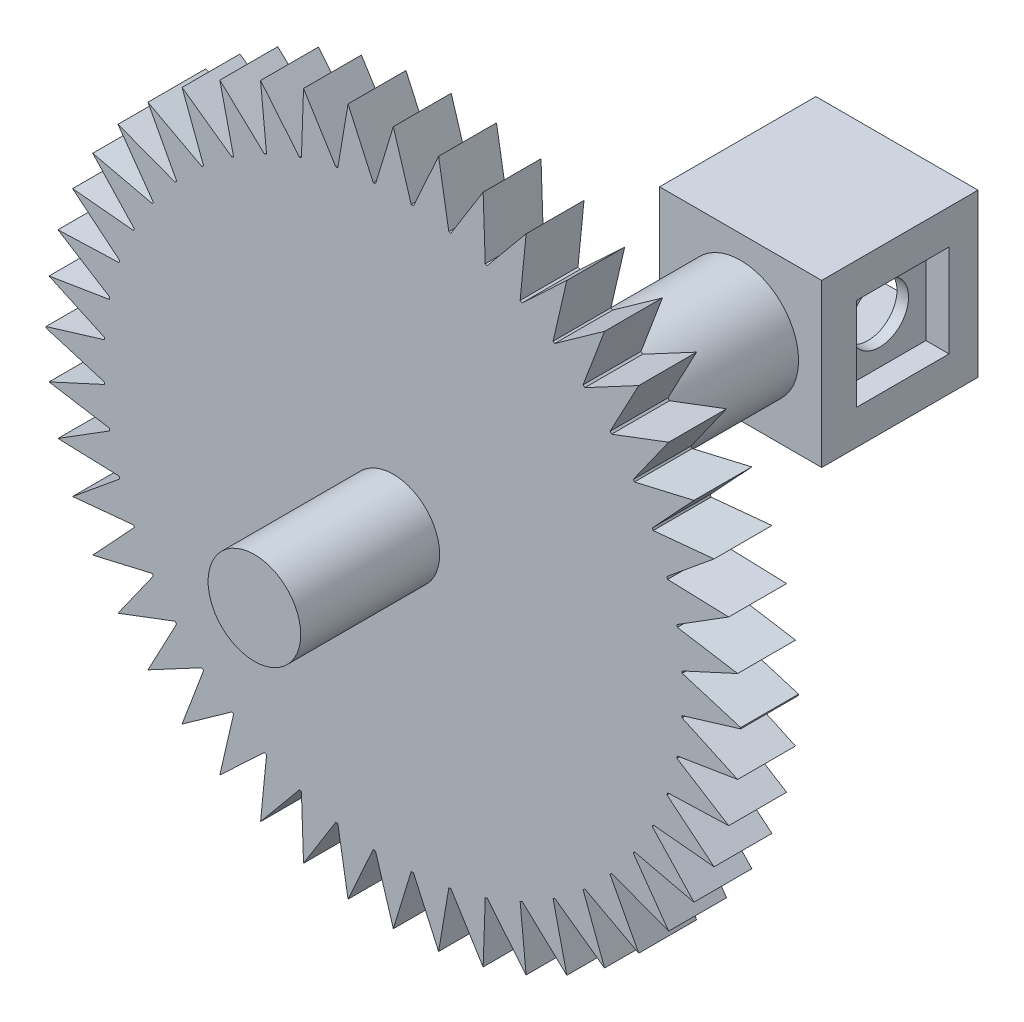
from build123d import *

# Parameters (mm, degrees)
ESQUISSE1_R             = 5
BOSS_EXTRU_1_DEPTH      = 70
ESQUISSE2_R             = 30
BOSS_EXTRU_2_DEPTH      = 5
ESQUISSE3_R             = 3.5
BOSS_EXTRU_3_DEPTH      = 12
ESQUISSE4_R             = 3.5
BOSS_EXTRU_4_DEPTH      = 12
ENL_V_MAT_EXTRU_1_DEPTH = 10
ESQUISSE6_R             = 5
ENL_V_MAT_EXTRU_2_DEPTH = 47
ESQUISSE7_R             = 4
BOSS_EXTRU_5_DEPTH      = 12
ESQUISSE8_R             = 5
ENL_V_MAT_EXTRU_3_DEPTH = 5
ESQUISSE9_W             = 14
ESQUISSE9_H             = 14
BOSS_EXTRU_6_DEPTH      = 13.5
ESQUISSE10_W            = 8
ESQUISSE10_H            = 8
ENL_V_MAT_EXTRU_4_DEPTH = 12
ESQUISSE11_W            = 8
ESQUISSE11_H            = 8
ENL_V_MAT_EXTRU_5_DEPTH = 2
ESQUISSE12_R            = 2.5
ENL_V_MAT_EXTRU_6_DEPTH = 2
ESQUISSE13_W            = 8
ESQUISSE13_H            = 8
ENL_V_MAT_EXTRU_7_DEPTH = 2
ESQUISSE14_R            = 2.5
ENL_V_MAT_EXTRU_8_DEPTH = 2


with BuildPart() as part:
    # Esquisse1 → Boss.-Extru.1 (new body)
    with BuildSketch(Plane.XY):
        Circle(ESQUISSE1_R)
    extrude(amount=BOSS_EXTRU_1_DEPTH)

    # Esquisse2 → Boss.-Extru.2 (add)
    with BuildSketch(Plane.XY.offset(70)):
        Circle(ESQUISSE2_R)
    extrude(amount=-BOSS_EXTRU_2_DEPTH)

    # Esquisse3 → Boss.-Extru.3 (add)
    with BuildSketch(Plane(origin=(0, 0, 0), x_dir=(-1, 0, 0), z_dir=(0, 0, -1))):
        Circle(ESQUISSE3_R)
    extrude(amount=BOSS_EXTRU_3_DEPTH)

    # Esquisse4 → Boss.-Extru.4 (add)
    with BuildSketch(Plane.XY.offset(70)):
        Circle(ESQUISSE4_R)
    extrude(amount=BOSS_EXTRU_4_DEPTH)

    # Esquisse5 → Enlèv. mat.-Extru.1 (cut)
    with BuildSketch(Plane.XY.offset(70)):
        with BuildLine():
            ThreePointArc((3.911624902, 29.743893333), (1.96, 29.935904864), (0, 30))
            Line((0, 30), (1.54, 24.952522919))
            ThreePointArc((1.54, 24.952522919), (1.639797772, 24.946163298), (1.739569306, 24.939404536))
            Line((1.739569306, 24.939404536), (3.911624902, 29.743893333))
        make_face()
        with BuildLine():
            Line((-1.54, 24.952522919), (0, 30))
            ThreePointArc((0, 30), (-1.96, 29.935904864), (-3.911624902, 29.743893333))
            Line((-3.911624902, 29.743893333), (-1.739569306, 24.939404536))
            ThreePointArc((-1.739569306, 24.939404536), (-1.639797772, 24.946163298), (-1.54, 24.952522919))
        make_face()
        with BuildLine():
            ThreePointArc((7.75646359, 28.979946042), (5.846535396, 29.424785876), (3.911624902, 29.743893333))
            Line((3.911624902, 29.743893333), (4.793067146, 24.536228466))
            ThreePointArc((4.793067146, 24.536228466), (4.878466786, 24.519391547), (4.963807286, 24.50225739))
            Line((4.963807286, 24.50225739), (7.75646359, 28.979946042))
        make_face()
        with BuildLine():
            Line((-4.793067146, 24.536228466), (-3.911624902, 29.743893333))
            ThreePointArc((-3.911624902, 29.743893333), (-5.846535396, 29.424785876), (-7.75646359, 28.979946042))
            Line((-7.75646359, 28.979946042), (-4.963807286, 24.50225739))
            ThreePointArc((-4.963807286, 24.50225739), (-4.878466786, 24.519391547), (-4.793067146, 24.536228466))
        make_face()
        with BuildLine():
            ThreePointArc((11.468870142, 27.721201591), (9.633248345, 28.411274634), (7.75646359, 28.979946042))
            Line((7.75646359, 28.979946042), (7.939081747, 23.705927128))
            ThreePointArc((7.939081747, 23.705927128), (8.021571427, 23.678141647), (8.103963866, 23.650069126))
            Line((8.103963866, 23.650069126), (11.468870142, 27.721201591))
        make_face()
        with BuildLine():
            Line((-7.939081747, 23.705927128), (-7.75646359, 28.979946042))
            ThreePointArc((-7.75646359, 28.979946042), (-9.633248345, 28.411274634), (-11.468870142, 27.721201591))
            Line((-11.468870142, 27.721201591), (-8.103963866, 23.650069126))
            ThreePointArc((-8.103963866, 23.650069126), (-8.021571427, 23.678141647), (-7.939081747, 23.705927128))
        make_face()
        with BuildLine():
            ThreePointArc((14.985459754, 25.989151505), (13.255485353, 26.912675602), (11.468870142, 27.721201591))
            Line((11.468870142, 27.721201591), (10.950617091, 22.474073626))
            ThreePointArc((10.950617091, 22.474073626), (11.04042578, 22.430091364), (11.130057821, 22.38575022))
            Line((11.130057821, 22.38575022), (14.985459754, 25.989151505))
        make_face()
        with BuildLine():
            Line((-10.950617091, 22.474073626), (-11.468870142, 27.721201591))
            ThreePointArc((-11.468870142, 27.721201591), (-13.255485353, 26.912675602), (-14.985459754, 25.989151505))
            Line((-14.985459754, 25.989151505), (-11.130057821, 22.38575022))
            ThreePointArc((-11.130057821, 22.38575022), (-11.04042578, 22.430091364), (-10.950617091, 22.474073626))
        make_face()
        with BuildLine():
            ThreePointArc((18.246190956, 23.813368422), (16.65140115, 24.954575527), (14.985459754, 25.989151505))
            Line((14.985459754, 25.989151505), (13.798277376, 20.847243018))
            ThreePointArc((13.798277376, 20.847243018), (13.870778356, 20.799074686), (13.943111187, 20.750654217))
            Line((13.943111187, 20.750654217), (18.246190956, 23.813368422))
        make_face()
        with BuildLine():
            Line((-13.798277376, 20.847243018), (-14.985459754, 25.989151505))
            ThreePointArc((-14.985459754, 25.989151505), (-16.65140115, 24.954575527), (-18.246190956, 23.813368422))
            Line((-18.246190956, 23.813368422), (-13.943111187, 20.750654217))
            ThreePointArc((-13.943111187, 20.750654217), (-13.870778356, 20.799074686), (-13.798277376, 20.847243018))
        make_face()
        with BuildLine():
            ThreePointArc((21.195390749, 21.231001177), (19.763014623, 22.570406576), (18.246190956, 23.813368422))
            Line((18.246190956, 23.813368422), (16.388920873, 18.878645942))
            ThreePointArc((16.388920873, 18.878645942), (16.464304345, 18.812939229), (16.539424387, 18.746931507))
            Line((16.539424387, 18.746931507), (21.195390749, 21.231001177))
        make_face()
        with BuildLine():
            Line((-16.388920873, 18.878645942), (-18.246190956, 23.813368422))
            ThreePointArc((-18.246190956, 23.813368422), (-19.763014623, 22.570406576), (-21.195390749, 21.231001177))
            Line((-21.195390749, 21.231001177), (-16.539424387, 18.746931507))
            ThreePointArc((-16.539424387, 18.746931507), (-16.464304345, 18.812939229), (-16.388920873, 18.878645942))
        make_face()
        with BuildLine():
            ThreePointArc((23.78270515, 18.286140537), (22.537198777, 19.800875518), (21.195390749, 21.231001177))
            Line((21.195390749, 21.231001177), (18.719140508, 16.57087139))
            ThreePointArc((18.719140508, 16.57087139), (18.78527424, 16.495862261), (18.851107406, 16.420589196))
            Line((18.851107406, 16.420589196), (23.78270515, 18.286140537))
        make_face()
        with BuildLine():
            Line((-18.719140508, 16.57087139), (-21.195390749, 21.231001177))
            ThreePointArc((-21.195390749, 21.231001177), (-22.537198777, 19.800875518), (-23.78270515, 18.286140537))
            Line((-23.78270515, 18.286140537), (-18.851107406, 16.420589196))
            ThreePointArc((-18.851107406, 16.420589196), (-18.78527424, 16.495862261), (-18.719140508, 16.57087139))
        make_face()
        with BuildLine():
            ThreePointArc((25.963958928, 15.029066397), (24.926587807, 16.693268712), (23.78270515, 18.286140537))
            Line((23.78270515, 18.286140537), (20.727218802, 13.97792548))
            ThreePointArc((20.727218802, 13.97792548), (20.775760628, 13.905674034), (20.824050599, 13.833254016))
            Line((20.824050599, 13.833254016), (25.963958928, 15.029066397))
        make_face()
        with BuildLine():
            Line((-20.727218802, 13.97792548), (-23.78270515, 18.286140537))
            ThreePointArc((-23.78270515, 18.286140537), (-24.926587807, 16.693268712), (-25.963958928, 15.029066397))
            Line((-25.963958928, 15.029066397), (-20.824050599, 13.833254016))
            ThreePointArc((-20.824050599, 13.833254016), (-20.775760628, 13.905674034), (-20.727218802, 13.97792548))
        make_face()
        with BuildLine():
            ThreePointArc((27.701909842, 11.515389317), (26.890385817, 13.300644745), (25.963958928, 15.029066397))
            Line((25.963958928, 15.029066397), (22.367034749, 11.167620899))
            ThreePointArc((22.367034749, 11.167620899), (22.405781894, 11.089677079), (22.444257425, 11.011598824))
            Line((22.444257425, 11.011598824), (27.701909842, 11.515389317))
        make_face()
        with BuildLine():
            Line((-22.367034749, 11.167620899), (-25.963958928, 15.029066397))
            ThreePointArc((-25.963958928, 15.029066397), (-26.890385817, 13.300644745), (-27.701909842, 11.515389317))
            Line((-27.701909842, 11.515389317), (-22.444257425, 11.011598824))
            ThreePointArc((-22.444257425, 11.011598824), (-22.405781894, 11.089677079), (-22.367034749, 11.167620899))
        make_face()
        with BuildLine():
            ThreePointArc((28.966884502, 7.805101039), (28.395063354, 9.680928526), (27.701909842, 11.515389317))
            Line((27.701909842, 11.515389317), (23.627977885, 8.168149181))
            ThreePointArc((23.627977885, 8.168149181), (23.660461458, 8.073571924), (23.692566461, 7.97886549))
            Line((23.692566461, 7.97886549), (28.966884502, 7.805101039))
        make_face()
        with BuildLine():
            Line((-23.627977885, 8.168149181), (-27.701909842, 11.515389317))
            ThreePointArc((-27.701909842, 11.515389317), (-28.395063354, 9.680928526), (-28.966884502, 7.805101039))
            Line((-28.966884502, 7.805101039), (-23.692566461, 7.97886549))
            ThreePointArc((-23.692566461, 7.97886549), (-23.660461458, 8.073571924), (-23.627977885, 8.168149181))
        make_face()
        with BuildLine():
            ThreePointArc((29.737285014, 3.9615502), (29.41492989, 5.895922284), (28.966884502, 7.805101039))
            Line((28.966884502, 7.805101039), (24.493890167, 5.004932014))
            ThreePointArc((24.493890167, 5.004932014), (24.513713944, 4.906916414), (24.533145499, 4.808822302))
            Line((24.533145499, 4.808822302), (29.737285014, 3.9615502))
        make_face()
        with BuildLine():
            Line((-24.493890167, 5.004932014), (-28.966884502, 7.805101039))
            ThreePointArc((-28.966884502, 7.805101039), (-29.41492989, 5.895922284), (-29.737285014, 3.9615502))
            Line((-29.737285014, 3.9615502), (-24.533145499, 4.808822302))
            ThreePointArc((-24.533145499, 4.808822302), (-24.513713944, 4.906916414), (-24.493890167, 5.004932014))
        make_face()
        with BuildLine():
            ThreePointArc((29.99995773, 0.050360733), (29.932572449, 2.010250376), (29.737285014, 3.9615502))
            Line((29.737285014, 3.9615502), (24.938282315, 1.755583995))
            ThreePointArc((24.938282315, 1.755583995), (24.944243639, 1.668744817), (24.949902576, 1.581885408))
            Line((24.949902576, 1.581885408), (29.99995773, 0.050360733))
        make_face()
        with BuildLine():
            Line((-24.938282315, 1.755583995), (-29.737285014, 3.9615502))
            ThreePointArc((-29.737285014, 3.9615502), (-29.932572449, 2.010250376), (-29.99995773, 0.050360733))
            Line((-29.99995773, 0.050360733), (-24.949902576, 1.581885408))
            ThreePointArc((-24.949902576, 1.581885408), (-24.944243639, 1.668744817), (-24.938282315, 1.755583995))
        make_face()
        with BuildLine():
            Line((-24.949902576, -1.581885408), (-29.99995773, -0.050360733))
            ThreePointArc((-29.99995773, -0.050360733), (-29.932572449, -2.010250376), (-29.737285014, -3.9615502))
            Line((-29.737285014, -3.9615502), (-24.938282315, -1.755583995))
            ThreePointArc((-24.938282315, -1.755583995), (-24.944243639, -1.668744817), (-24.949902576, -1.581885408))
        make_face()
        with BuildLine():
            ThreePointArc((29.737285014, -3.9615502), (29.932572449, -2.010250376), (29.99995773, -0.050360733))
            Line((29.99995773, -0.050360733), (24.949902576, -1.581885408))
            ThreePointArc((24.949902576, -1.581885408), (24.944243639, -1.668744817), (24.938282315, -1.755583995))
            Line((24.938282315, -1.755583995), (29.737285014, -3.9615502))
        make_face()
        with BuildLine():
            Line((-24.533145499, -4.808822302), (-29.737285014, -3.9615502))
            ThreePointArc((-29.737285014, -3.9615502), (-29.41492989, -5.895922284), (-28.966884502, -7.805101039))
            Line((-28.966884502, -7.805101039), (-24.493890167, -5.004932014))
            ThreePointArc((-24.493890167, -5.004932014), (-24.513713944, -4.906916414), (-24.533145499, -4.808822302))
        make_face()
        with BuildLine():
            ThreePointArc((28.966884502, -7.805101039), (29.41492989, -5.895922284), (29.737285014, -3.9615502))
            Line((29.737285014, -3.9615502), (24.533145499, -4.808822302))
            ThreePointArc((24.533145499, -4.808822302), (24.513713944, -4.906916414), (24.493890167, -5.004932014))
            Line((24.493890167, -5.004932014), (28.966884502, -7.805101039))
        make_face()
        with BuildLine():
            Line((-23.692566461, -7.97886549), (-28.966884502, -7.805101039))
            ThreePointArc((-28.966884502, -7.805101039), (-28.395063354, -9.680928526), (-27.701909842, -11.515389317))
            Line((-27.701909842, -11.515389317), (-23.627977885, -8.168149181))
            ThreePointArc((-23.627977885, -8.168149181), (-23.660461458, -8.073571924), (-23.692566461, -7.97886549))
        make_face()
        with BuildLine():
            ThreePointArc((27.701909842, -11.515389317), (28.395063354, -9.680928526), (28.966884502, -7.805101039))
            Line((28.966884502, -7.805101039), (23.692566461, -7.97886549))
            ThreePointArc((23.692566461, -7.97886549), (23.660461458, -8.073571924), (23.627977885, -8.168149181))
            Line((23.627977885, -8.168149181), (27.701909842, -11.515389317))
        make_face()
        with BuildLine():
            Line((-22.444257425, -11.011598824), (-27.701909842, -11.515389317))
            ThreePointArc((-27.701909842, -11.515389317), (-26.890385817, -13.300644745), (-25.963958928, -15.029066397))
            Line((-25.963958928, -15.029066397), (-22.367034749, -11.167620899))
            ThreePointArc((-22.367034749, -11.167620899), (-22.405781894, -11.089677079), (-22.444257425, -11.011598824))
        make_face()
        with BuildLine():
            ThreePointArc((25.963958928, -15.029066397), (26.890385817, -13.300644745), (27.701909842, -11.515389317))
            Line((27.701909842, -11.515389317), (22.444257425, -11.011598824))
            ThreePointArc((22.444257425, -11.011598824), (22.405781894, -11.089677079), (22.367034749, -11.167620899))
            Line((22.367034749, -11.167620899), (25.963958928, -15.029066397))
        make_face()
        with BuildLine():
            Line((-20.824050599, -13.833254016), (-25.963958928, -15.029066397))
            ThreePointArc((-25.963958928, -15.029066397), (-24.926587807, -16.693268712), (-23.78270515, -18.286140537))
            Line((-23.78270515, -18.286140537), (-20.727218802, -13.97792548))
            ThreePointArc((-20.727218802, -13.97792548), (-20.775760628, -13.905674034), (-20.824050599, -13.833254016))
        make_face()
        with BuildLine():
            ThreePointArc((23.78270515, -18.286140537), (24.926587807, -16.693268712), (25.963958928, -15.029066397))
            Line((25.963958928, -15.029066397), (20.824050599, -13.833254016))
            ThreePointArc((20.824050599, -13.833254016), (20.775760628, -13.905674034), (20.727218802, -13.97792548))
            Line((20.727218802, -13.97792548), (23.78270515, -18.286140537))
        make_face()
        with BuildLine():
            Line((-18.851107406, -16.420589196), (-23.78270515, -18.286140537))
            ThreePointArc((-23.78270515, -18.286140537), (-22.537198777, -19.800875518), (-21.195390749, -21.231001177))
            Line((-21.195390749, -21.231001177), (-18.719140508, -16.57087139))
            ThreePointArc((-18.719140508, -16.57087139), (-18.78527424, -16.495862261), (-18.851107406, -16.420589196))
        make_face()
        with BuildLine():
            ThreePointArc((21.195390749, -21.231001177), (22.537198777, -19.800875518), (23.78270515, -18.286140537))
            Line((23.78270515, -18.286140537), (18.851107406, -16.420589196))
            ThreePointArc((18.851107406, -16.420589196), (18.78527424, -16.495862261), (18.719140508, -16.57087139))
            Line((18.719140508, -16.57087139), (21.195390749, -21.231001177))
        make_face()
        with BuildLine():
            Line((-16.539424387, -18.746931507), (-21.195390749, -21.231001177))
            ThreePointArc((-21.195390749, -21.231001177), (-19.763014623, -22.570406576), (-18.246190956, -23.813368422))
            Line((-18.246190956, -23.813368422), (-16.388920873, -18.878645942))
            ThreePointArc((-16.388920873, -18.878645942), (-16.464304345, -18.812939229), (-16.539424387, -18.746931507))
        make_face()
        with BuildLine():
            ThreePointArc((18.246190956, -23.813368422), (19.763014623, -22.570406576), (21.195390749, -21.231001177))
            Line((21.195390749, -21.231001177), (16.539424387, -18.746931507))
            ThreePointArc((16.539424387, -18.746931507), (16.464304345, -18.812939229), (16.388920873, -18.878645942))
            Line((16.388920873, -18.878645942), (18.246190956, -23.813368422))
        make_face()
        with BuildLine():
            Line((-13.943111187, -20.750654217), (-18.246190956, -23.813368422))
            ThreePointArc((-18.246190956, -23.813368422), (-16.65140115, -24.954575527), (-14.985459754, -25.989151505))
            Line((-14.985459754, -25.989151505), (-13.798277376, -20.847243018))
            ThreePointArc((-13.798277376, -20.847243018), (-13.870778356, -20.799074686), (-13.943111187, -20.750654217))
        make_face()
        with BuildLine():
            ThreePointArc((14.985459754, -25.989151505), (16.65140115, -24.954575527), (18.246190956, -23.813368422))
            Line((18.246190956, -23.813368422), (13.943111187, -20.750654217))
            ThreePointArc((13.943111187, -20.750654217), (13.870778356, -20.799074686), (13.798277376, -20.847243018))
            Line((13.798277376, -20.847243018), (14.985459754, -25.989151505))
        make_face()
        with BuildLine():
            Line((-11.130057821, -22.38575022), (-14.985459754, -25.989151505))
            ThreePointArc((-14.985459754, -25.989151505), (-13.255485353, -26.912675602), (-11.468870142, -27.721201591))
            Line((-11.468870142, -27.721201591), (-10.950617091, -22.474073626))
            ThreePointArc((-10.950617091, -22.474073626), (-11.04042578, -22.430091364), (-11.130057821, -22.38575022))
        make_face()
        with BuildLine():
            ThreePointArc((11.468870142, -27.721201591), (13.255485353, -26.912675602), (14.985459754, -25.989151505))
            Line((14.985459754, -25.989151505), (11.130057821, -22.38575022))
            ThreePointArc((11.130057821, -22.38575022), (11.04042578, -22.430091364), (10.950617091, -22.474073626))
            Line((10.950617091, -22.474073626), (11.468870142, -27.721201591))
        make_face()
        with BuildLine():
            Line((-8.103963866, -23.650069126), (-11.468870142, -27.721201591))
            ThreePointArc((-11.468870142, -27.721201591), (-9.633248345, -28.411274634), (-7.75646359, -28.979946042))
            Line((-7.75646359, -28.979946042), (-7.939081747, -23.705927128))
            ThreePointArc((-7.939081747, -23.705927128), (-8.021571427, -23.678141647), (-8.103963866, -23.650069126))
        make_face()
        with BuildLine():
            ThreePointArc((7.75646359, -28.979946042), (9.633248345, -28.411274634), (11.468870142, -27.721201591))
            Line((11.468870142, -27.721201591), (8.103963866, -23.650069126))
            ThreePointArc((8.103963866, -23.650069126), (8.021571427, -23.678141647), (7.939081747, -23.705927128))
            Line((7.939081747, -23.705927128), (7.75646359, -28.979946042))
        make_face()
        with BuildLine():
            Line((-4.963807286, -24.50225739), (-7.75646359, -28.979946042))
            ThreePointArc((-7.75646359, -28.979946042), (-5.846535396, -29.424785876), (-3.911624902, -29.743893333))
            Line((-3.911624902, -29.743893333), (-4.793067146, -24.536228466))
            ThreePointArc((-4.793067146, -24.536228466), (-4.878466786, -24.519391547), (-4.963807286, -24.50225739))
        make_face()
        with BuildLine():
            ThreePointArc((3.911624902, -29.743893333), (5.846535396, -29.424785876), (7.75646359, -28.979946042))
            Line((7.75646359, -28.979946042), (4.963807286, -24.50225739))
            ThreePointArc((4.963807286, -24.50225739), (4.878466786, -24.519391547), (4.793067146, -24.536228466))
            Line((4.793067146, -24.536228466), (3.911624902, -29.743893333))
        make_face()
        with BuildLine():
            Line((-1.739569306, -24.939404536), (-3.911624902, -29.743893333))
            ThreePointArc((-3.911624902, -29.743893333), (-1.96, -29.935904864), (0, -30))
            Line((0, -30), (-1.54, -24.952522919))
            ThreePointArc((-1.54, -24.952522919), (-1.639797772, -24.946163298), (-1.739569306, -24.939404536))
        make_face()
        with BuildLine():
            ThreePointArc((0, -30), (1.96, -29.935904864), (3.911624902, -29.743893333))
            Line((3.911624902, -29.743893333), (1.739569306, -24.939404536))
            ThreePointArc((1.739569306, -24.939404536), (1.639797772, -24.946163298), (1.54, -24.952522919))
            Line((1.54, -24.952522919), (0, -30))
        make_face()
    extrude(amount=-ENL_V_MAT_EXTRU_1_DEPTH, mode=Mode.SUBTRACT)

    # Esquisse6 → Enlèv. mat.-Extru.2 (cut)
    with BuildSketch(Plane(origin=(0, 0, -12), x_dir=(-1, 0, 0), z_dir=(0, 0, -1))):
        Circle(ESQUISSE6_R)
    extrude(amount=-ENL_V_MAT_EXTRU_2_DEPTH, mode=Mode.SUBTRACT)

    # Esquisse7 → Boss.-Extru.5 (add)
    with BuildSketch(Plane.XY.offset(82)):
        Circle(ESQUISSE7_R)
    extrude(amount=-BOSS_EXTRU_5_DEPTH)

    # Esquisse8 → Enlèv. mat.-Extru.3 (cut)
    with BuildSketch(Plane(origin=(0, 0, 35), x_dir=(-1, 0, 0), z_dir=(0, 0, -1))):
        Circle(ESQUISSE8_R)
    extrude(amount=-ENL_V_MAT_EXTRU_3_DEPTH, mode=Mode.SUBTRACT)

    # Esquisse9 → Boss.-Extru.6 (add)
    with BuildSketch(Plane(origin=(0, 0, 40), x_dir=(-1, 0, 0), z_dir=(0, 0, -1))):
        Rectangle(ESQUISSE9_W, ESQUISSE9_H)
    extrude(amount=BOSS_EXTRU_6_DEPTH)

    # Esquisse10 → Enlèv. mat.-Extru.4 (cut)
    with BuildSketch(Plane(origin=(0, 0, 26.5), x_dir=(-1, 0, 0), z_dir=(0, 0, -1))):
        Rectangle(ESQUISSE10_W, ESQUISSE10_H)
    extrude(amount=-ENL_V_MAT_EXTRU_4_DEPTH, mode=Mode.SUBTRACT)

    # Esquisse11 → Enlèv. mat.-Extru.5 (cut)
    with BuildSketch(Plane.ZY.offset(7)):
        with Locations((33, 0)):
            Rectangle(ESQUISSE11_W, ESQUISSE11_H)
    extrude(amount=-ENL_V_MAT_EXTRU_5_DEPTH, mode=Mode.SUBTRACT)

    # Esquisse12 → Enlèv. mat.-Extru.6 (cut)
    with BuildSketch(Plane.ZY.offset(5)):
        with Locations((33, 0)):
            Circle(ESQUISSE12_R)
    extrude(amount=-ENL_V_MAT_EXTRU_6_DEPTH, mode=Mode.SUBTRACT)

    # Esquisse13 → Enlèv. mat.-Extru.7 (cut)
    with BuildSketch(Plane(origin=(7, 0, 0), x_dir=(0, 0, -1), z_dir=(1, 0, 0))):
        with Locations((-33, 0)):
            Rectangle(ESQUISSE13_W, ESQUISSE13_H)
    extrude(amount=-ENL_V_MAT_EXTRU_7_DEPTH, mode=Mode.SUBTRACT)

    # Esquisse14 → Enlèv. mat.-Extru.8 (cut)
    with BuildSketch(Plane(origin=(5, 0, 0), x_dir=(0, 0, -1), z_dir=(1, 0, 0))):
        with Locations((-33, 0)):
            Circle(ESQUISSE14_R)
    extrude(amount=-ENL_V_MAT_EXTRU_8_DEPTH, mode=Mode.SUBTRACT)


solid = part.part
